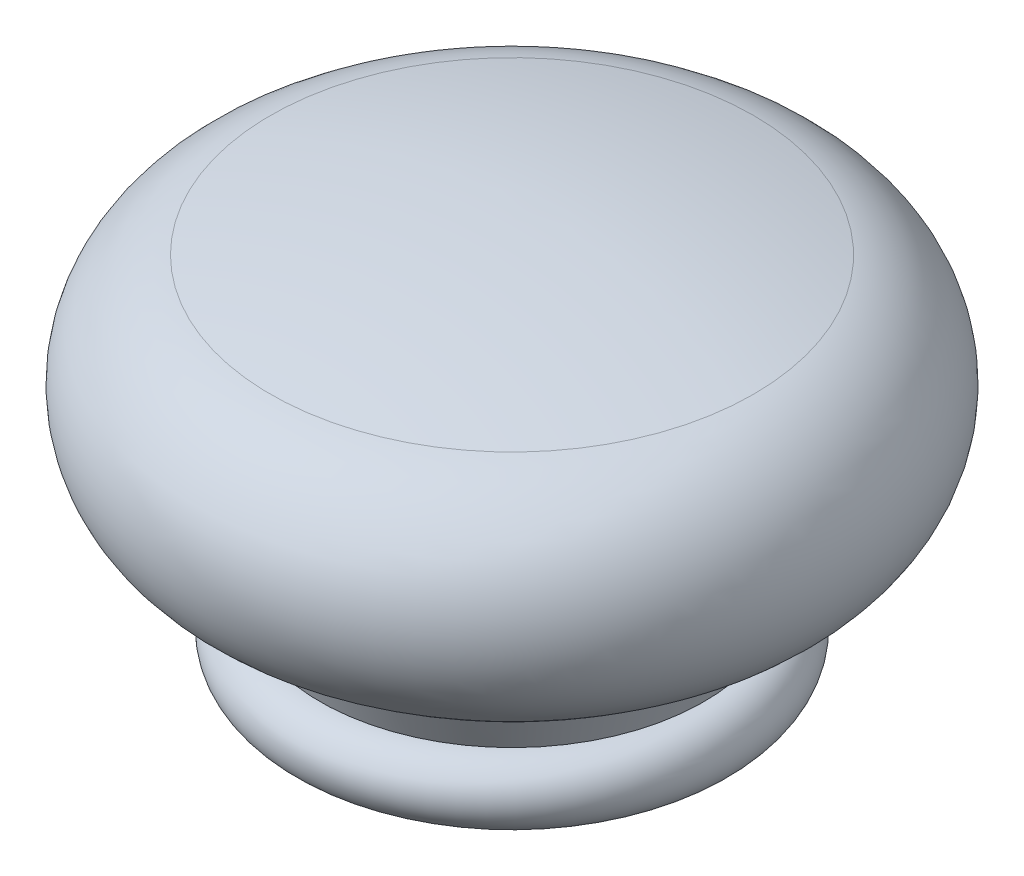
from build123d import *


with BuildPart() as part:
    # Croquis1 → Revolución1 (revolve)
    with BuildSketch(Plane.XY):
        with BuildLine():
            Line((5, 0), (15, 0))
            ThreePointArc((15, 0), (17.5, 2.5), (15, 5))
            Line((15, 5), (17, 9.999396685))
            ThreePointArc((17, 9.999396685), (25.700254064, 18.050962315), (18.873239437, 27.741885964))
            ThreePointArc((18.873239437, 27.741885964), (9.503923477, 29.433465482), (0, 30))
            Line((0, 30), (0, 10))
            Line((0, 10), (5, 10))
            Line((5, 10), (5, 0))
        make_face()
    revolve(axis=Axis((0, -10.165252064, 0), (0, 1, 0)))


solid = part.part
